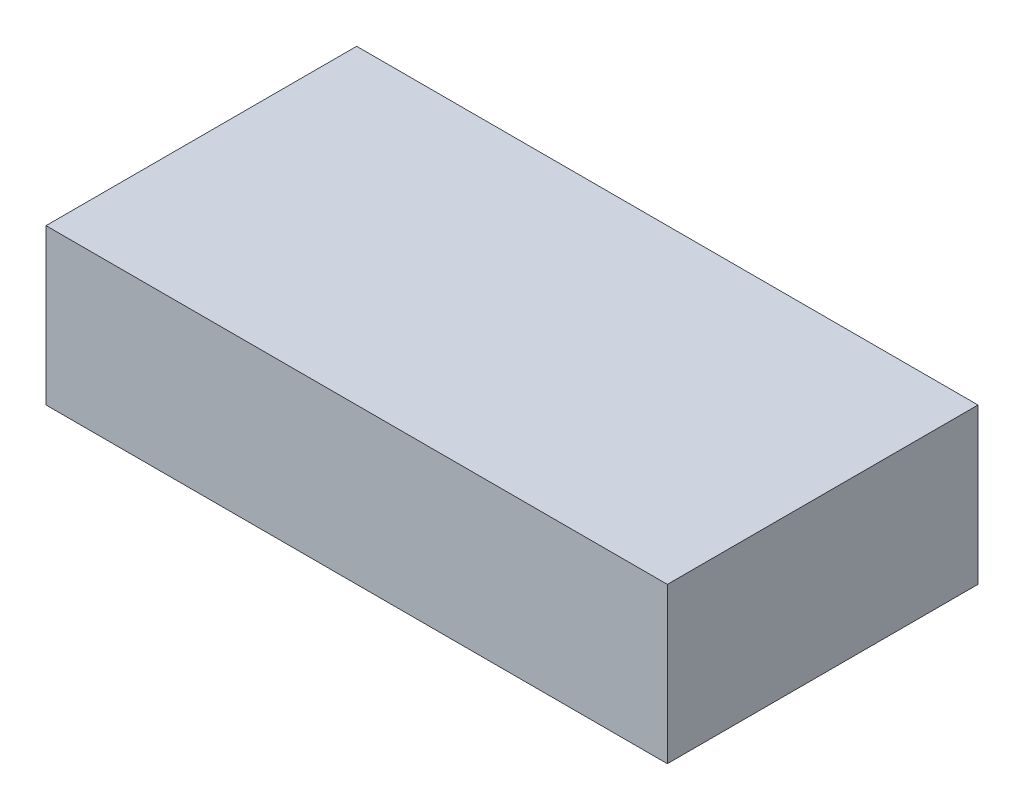
from build123d import *

# Parameters (mm, degrees)
SKETCH1_W           = 1
SKETCH1_H           = 0.5
BOSS_EXTRUDE1_DEPTH = 0.25


with BuildPart() as part:
    # Sketch1 → Boss-Extrude1 (new body)
    with BuildSketch(Plane(origin=(0, 0, 0), x_dir=(1, 0, 0), z_dir=(0, 1, 0))):
        Rectangle(SKETCH1_W, SKETCH1_H)
    extrude(amount=BOSS_EXTRUDE1_DEPTH)


solid = part.part
